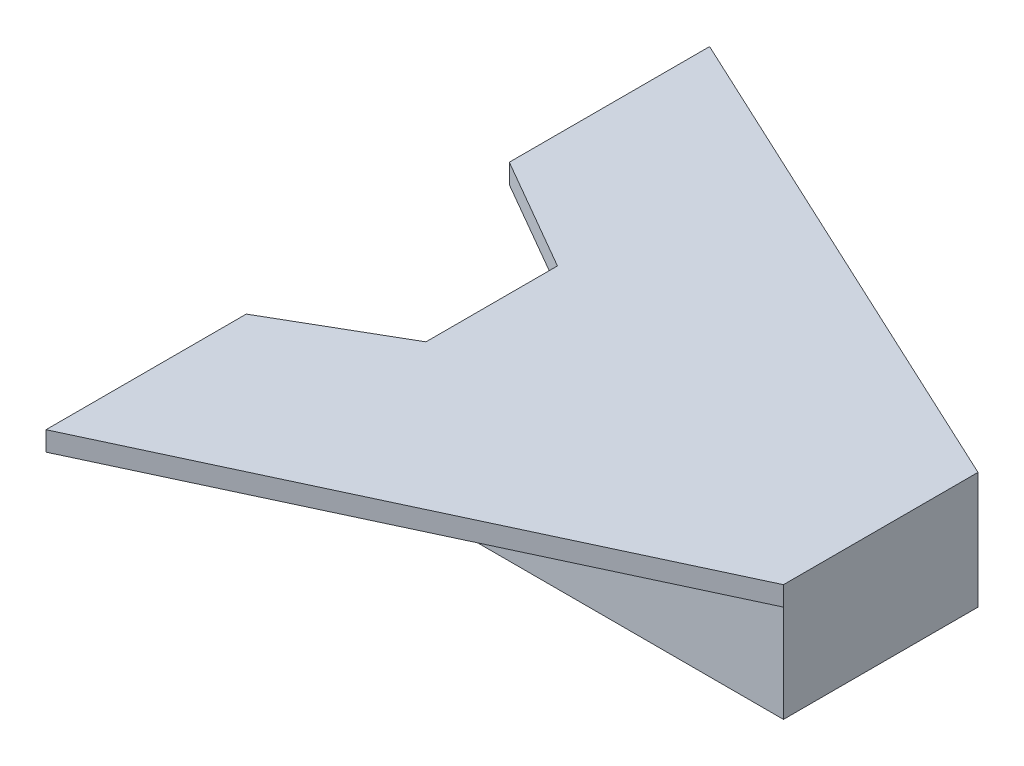
from build123d import *

# Parameters (mm, degrees)
BOSS_EXTRUDE1_DEPTH = 50
SKETCH2_W           = 950
SKETCH2_H           = 500
BOSS_EXTRUDE2_DEPTH = 250
SKETCH3_R           = 5
CUT_EXTRUDE1_DEPTH  = 500
SKETCH4_W           = 11.538461538
SKETCH4_H           = 3.076923077
BOSS_EXTRUDE3_DEPTH = 3


with BuildPart() as part:
    # Sketch1 → Boss-Extrude1 (new body)
    with BuildSketch(Plane(origin=(0, 0, 0), x_dir=(1, 0, 0), z_dir=(0, 1, 0))):
        Polygon((-1000, 500), (0, 500), (-1292.759621171, 1102.823711506), (-1292.759621171, 588.049692182), (-1000, 419.024846091), align=None)
        Polygon((0, 0), (0, 500), (-1000, 500), (-1000, 419.024846091), (-1000, 80.975153909), (-1000, 0), align=None)
        Polygon((-1292.759621171, -602.823711506), (0, 0), (-1000, 0), (-1000, 80.975153909), (-1292.759621171, -88.049692182), align=None)
    extrude(amount=BOSS_EXTRUDE1_DEPTH)

    # Sketch2 → Boss-Extrude2 (add)
    with BuildSketch(Plane.XZ):
        with Locations((-475, -250)):
            Rectangle(SKETCH2_W, SKETCH2_H)
    extrude(amount=BOSS_EXTRUDE2_DEPTH)

    # Sketch3 → Cut-Extrude1 (cut)
    with BuildSketch(Plane.XY):
        with Locations((-700, -170)):
            Circle(SKETCH3_R)
    extrude(amount=-CUT_EXTRUDE1_DEPTH, mode=Mode.SUBTRACT)

    # Sketch4 → Boss-Extrude3 (add)
    with BuildSketch(Plane.ZY.offset(950)):
        with BuildLine():
            Line((-305.64268199, -193.452389405), (-308.334989682, -193.452389405))
            add(Edge.make_bspline(
                [(-308.334989682, -193.452389405), (-308.317442657, -193.095210367), (-308.282980765, -192.393720242), (-308.121595428, -191.370943902), (-307.890673624, -190.393331341), (-307.564175447, -189.468732079), (-307.158693066, -188.588970874), (-306.672435688, -187.757542168), (-306.096488398, -186.977617693), (-305.44328782, -186.256427608), (-304.733842343, -185.594819858), (-303.968362862, -185.023489205), (-303.163976913, -184.540766308), (-302.323124922, -184.137212807), (-301.436320092, -183.834299842), (-300.511609882, -183.609542931), (-299.54493157, -183.47431711), (-298.886302809, -183.459781805), (-298.551335836, -183.452389405)],
                knots=[0, 0, 0, 0, 0.00107214, 0.002105654, 0.003101184, 0.004081912, 0.005041834, 0.006003467, 0.006966244, 0.007944944, 0.008918817, 0.009871943, 0.010804673, 0.011729393, 0.012664463, 0.013610438, 0.014581023, 0.01558551, 0.01558551, 0.01558551, 0.01558551], degree=3))
            add(Edge.make_bspline(
                [(-298.551335836, -183.452389405), (-298.222380915, -183.46009046), (-297.575996247, -183.475222759), (-296.632607552, -183.605174438), (-295.734516456, -183.808708081), (-294.883478457, -184.094268792), (-294.086283618, -184.478135313), (-293.336943236, -184.939257073), (-292.626536287, -185.472569913), (-291.98704957, -186.100459743), (-291.399837462, -186.770765895), (-290.893246704, -187.486376498), (-290.459419588, -188.225484661), (-290.097810904, -188.993726389), (-289.831615427, -189.798335204), (-289.629516501, -190.627596942), (-289.515281527, -191.490095322), (-289.497749325, -192.073865799), (-289.488835836, -192.370658636)],
                knots=[0, 0, 0, 0, 0.000986474, 0.001938387, 0.002850978, 0.003746088, 0.004625075, 0.005499097, 0.006382531, 0.007283573, 0.008182467, 0.009052929, 0.009909441, 0.010751002, 0.011594791, 0.0124475, 0.013308471, 0.014198888, 0.014198888, 0.014198888, 0.014198888], degree=3))
            add(Edge.make_bspline(
                [(-289.488835836, -192.370658636), (-289.503349518, -192.788497218), (-289.532122187, -193.616841907), (-289.778245414, -194.834112159), (-290.162644081, -196.013484322), (-290.625478568, -196.962661197), (-291.092385231, -197.727519715), (-291.513135297, -198.357251472), (-292.00569082, -199.035298344), (-292.577220802, -199.759389807), (-293.215902563, -200.535197565), (-293.927521106, -201.362252954), (-294.717150952, -202.232010981), (-295.271366673, -202.826058993), (-295.558547375, -203.13387979)],
                knots=[0, 0, 0, 0, 0.001252439, 0.0024829, 0.003710568, 0.004965773, 0.005639815, 0.006398194, 0.00723724, 0.008153308, 0.009165156, 0.010251767, 0.011426121, 0.012689069, 0.012689069, 0.012689069, 0.012689069], degree=3))
            Line((-295.558547375, -203.13387979), (-303.06455699, -211.144697097))
            Line((-303.06455699, -211.144697097), (-289.104220452, -211.144697097))
            Line((-289.104220452, -211.144697097), (-289.104220452, -214.221620174))
            Line((-289.104220452, -214.221620174), (-309.488835836, -214.221620174))
            Line((-309.488835836, -214.221620174), (-297.854220452, -201.80575479))
            add(Edge.make_bspline(
                [(-297.854220452, -201.80575479), (-297.57095285, -201.510055019), (-297.026853761, -200.942076277), (-296.257288817, -200.112850904), (-295.566097488, -199.343569127), (-294.94880555, -198.635684426), (-294.418804076, -197.978842416), (-293.948470659, -197.394316385), (-293.571622736, -196.856421097), (-293.16263363, -196.23293012), (-292.76651379, -195.471681688), (-292.426122167, -194.541392922), (-292.218566323, -193.583730757), (-292.193667733, -192.936570439), (-292.181143529, -192.611043251)],
                knots=[0, 0, 0, 0, 0.001228448, 0.002359598, 0.003393688, 0.004331034, 0.005176705, 0.005925692, 0.006580988, 0.007146084, 0.008162117, 0.009146888, 0.010111014, 0.011086814, 0.011086814, 0.011086814, 0.011086814], degree=3))
            add(Edge.make_bspline(
                [(-292.181143529, -192.611043251), (-292.186592748, -192.406345551), (-292.197332114, -192.00292569), (-292.292112378, -191.411447756), (-292.435345287, -190.840892209), (-292.640590356, -190.289504045), (-292.911505271, -189.762827027), (-293.241277099, -189.260220054), (-293.621763357, -188.774314638), (-294.061917094, -188.318714941), (-294.545444407, -187.901447465), (-295.056252261, -187.531812447), (-295.596681726, -187.222905783), (-296.164454201, -186.969675807), (-296.757986796, -186.771029683), (-297.378427469, -186.633384716), (-298.024061894, -186.546963425), (-298.464920429, -186.535270523), (-298.68955699, -186.529312482)],
                knots=[0, 0, 0, 0, 0.000613717, 0.001209518, 0.001792544, 0.002376343, 0.002970323, 0.003565396, 0.004177345, 0.004819137, 0.005462503, 0.006091248, 0.006707695, 0.007326422, 0.007953557, 0.008581928, 0.009230438, 0.009904185, 0.009904185, 0.009904185, 0.009904185], degree=3))
            add(Edge.make_bspline(
                [(-298.68955699, -186.529312482), (-298.924164128, -186.53544133), (-299.38489381, -186.547477376), (-300.061342664, -186.631671638), (-300.706649328, -186.776921699), (-301.322437068, -186.975578908), (-301.909747803, -187.228080755), (-302.465725324, -187.542581424), (-302.989121517, -187.917868508), (-303.480920289, -188.343358991), (-303.934040109, -188.817081287), (-304.332156188, -189.345166684), (-304.680019166, -189.917973102), (-304.983526882, -190.533954964), (-305.230004226, -191.19870165), (-305.418345515, -191.909853405), (-305.56737563, -192.664322389), (-305.617162949, -193.185337402), (-305.64268199, -193.452389405)],
                knots=[0, 0, 0, 0, 0.000703767, 0.001382082, 0.002041087, 0.002685351, 0.003320582, 0.00395567, 0.004597687, 0.00524953, 0.005904164, 0.006560424, 0.00722933, 0.007911997, 0.00861748, 0.009352228, 0.010117151, 0.010921497, 0.010921497, 0.010921497, 0.010921497], degree=3))
        make_face()
        Polygon((-283.719605067, -184.221620174), (-269.104220452, -184.221620174), (-269.104220452, -187.298543251), (-281.027297375, -187.298543251), (-281.027297375, -196.529312482), (-269.104220452, -196.529312482), (-269.104220452, -199.606235559), (-281.027297375, -199.606235559), (-281.027297375, -214.221620174), (-283.719605067, -214.221620174), align=None)
        with BuildLine():
            Line((-266.796528144, -208.434360559), (-264.260470452, -206.913927867))
            add(Edge.make_bspline(
                [(-264.260470452, -206.913927867), (-264.024599847, -207.308765452), (-263.57268087, -208.065259028), (-262.818812077, -209.087470803), (-262.037672838, -209.95628929), (-261.223478551, -210.666660212), (-260.381198996, -211.225936384), (-259.505335678, -211.621955513), (-258.598840157, -211.868949587), (-257.981921688, -211.898950329), (-257.67393199, -211.913927867)],
                knots=[0, 0, 0, 0, 0.001379151, 0.0026424, 0.003803812, 0.004877399, 0.005875827, 0.00682529, 0.007750887, 0.008673672, 0.008673672, 0.008673672, 0.008673672], degree=3))
            add(Edge.make_bspline(
                [(-257.67393199, -211.913927867), (-257.410901757, -211.906602102), (-256.889443702, -211.892078757), (-256.121767334, -211.752529025), (-255.376209029, -211.538139349), (-254.668134991, -211.231102793), (-254.007315438, -210.859630058), (-253.427829478, -210.410948537), (-252.926862794, -209.908609631), (-252.517070383, -209.348186877), (-252.202670081, -208.74546846), (-251.96102378, -208.126817449), (-251.826923149, -207.482515435), (-251.806722405, -207.048711468), (-251.796528144, -206.829793251)],
                knots=[0, 0, 0, 0, 0.000788383, 0.001562971, 0.002333163, 0.003111217, 0.003873017, 0.004601446, 0.005302617, 0.005994975, 0.006675125, 0.007337001, 0.007981713, 0.008638523, 0.008638523, 0.008638523, 0.008638523], degree=3))
            add(Edge.make_bspline(
                [(-251.796528144, -206.829793251), (-251.809165093, -206.58001454), (-251.834854163, -206.072250918), (-252.051981135, -205.323111036), (-252.393546108, -204.58174615), (-252.708654483, -204.123163874), (-252.872249298, -203.885081713)],
                knots=[0, 0, 0, 0, 0.000748119, 0.001520816, 0.00232208, 0.003187236, 0.003187236, 0.003187236, 0.003187236], degree=3))
            add(Edge.make_bspline(
                [(-252.872249298, -203.885081713), (-253.006568848, -203.713251796), (-253.288555942, -203.35251638), (-253.773334621, -202.815557219), (-254.342187029, -202.261685056), (-254.975646072, -201.669750282), (-255.696786833, -201.067283454), (-256.483022671, -200.425555357), (-257.354427176, -199.768970411), (-257.965565719, -199.328634135), (-258.280903144, -199.101427867)],
                knots=[0, 0, 0, 0, 0.000654165, 0.001373338, 0.002167995, 0.003035547, 0.003973548, 0.004986253, 0.006080019, 0.007246024, 0.007246024, 0.007246024, 0.007246024], degree=3))
            add(Edge.make_bspline(
                [(-258.280903144, -199.101427867), (-258.596537397, -198.876611401), (-259.200006053, -198.446779439), (-260.043936759, -197.808857005), (-260.798603585, -197.225623837), (-261.460652298, -196.691589448), (-262.029791699, -196.206681407), (-262.510506651, -195.775556215), (-262.890551426, -195.386554264), (-263.101884975, -195.134199907), (-263.196768529, -195.020899021)],
                knots=[0, 0, 0, 0, 0.001162484, 0.002222581, 0.00317343, 0.004023764, 0.004774028, 0.005416383, 0.005960377, 0.006403625, 0.006403625, 0.006403625, 0.006403625], degree=3))
            add(Edge.make_bspline(
                [(-263.196768529, -195.020899021), (-263.329390345, -194.844318705), (-263.590208945, -194.497049815), (-263.934488992, -193.95426532), (-264.227110387, -193.398637331), (-264.456501806, -192.828672777), (-264.649669396, -192.252373387), (-264.779594516, -191.662219852), (-264.860949347, -191.060860266), (-264.86928066, -190.656173117), (-264.873451221, -190.453591328)],
                knots=[0, 0, 0, 0, 0.000662313, 0.001302528, 0.001926139, 0.002543289, 0.00314383, 0.00374743, 0.004353448, 0.004960895, 0.004960895, 0.004960895, 0.004960895], degree=3))
            add(Edge.make_bspline(
                [(-264.873451221, -190.453591328), (-264.862263715, -190.136193261), (-264.840127829, -189.508181286), (-264.652923395, -188.590774168), (-264.35744145, -187.714890591), (-263.943485268, -186.889202017), (-263.409850814, -186.135207895), (-262.792313891, -185.444235149), (-262.056786866, -184.863361587), (-261.249764381, -184.355829658), (-260.366424049, -183.958578871), (-259.440787734, -183.658913327), (-258.47138426, -183.489119689), (-257.814785963, -183.464753133), (-257.481624298, -183.452389405)],
                knots=[0, 0, 0, 0, 0.000951419, 0.001882502, 0.002796616, 0.00371846, 0.004642066, 0.005560928, 0.006488222, 0.007443751, 0.008414597, 0.009385796, 0.010356028, 0.011355432, 0.011355432, 0.011355432, 0.011355432], degree=3))
            add(Edge.make_bspline(
                [(-257.481624298, -183.452389405), (-257.128103438, -183.464582705), (-256.42506328, -183.488831285), (-255.390927147, -183.699667268), (-254.395263863, -184.048530169), (-253.594321593, -184.444432952), (-252.967469352, -184.839845087), (-252.489417358, -185.200015009), (-252.004982065, -185.614658797), (-251.510255881, -186.084880906), (-251.013621657, -186.614995916), (-250.507706352, -187.201373249), (-249.991326905, -187.840429442), (-249.659133819, -188.296639449), (-249.488835836, -188.530514405)],
                knots=[0, 0, 0, 0, 0.001059756, 0.002107517, 0.003150925, 0.004217898, 0.004779757, 0.005372307, 0.006011759, 0.006691882, 0.007418847, 0.008189976, 0.009014959, 0.009882761, 0.009882761, 0.009882761, 0.009882761], degree=3))
            Line((-249.488835836, -188.530514405), (-251.922730067, -190.375466328))
            add(Edge.make_bspline(
                [(-251.922730067, -190.375466328), (-252.069695202, -190.186134696), (-252.352715692, -189.82152624), (-252.782397008, -189.310914963), (-253.187385418, -188.844487996), (-253.586388845, -188.439358327), (-253.958334258, -188.073340041), (-254.319337477, -187.759970697), (-254.664203345, -187.496179879), (-255.098919722, -187.214663651), (-255.645071593, -186.935607906), (-256.330653332, -186.699472951), (-257.047107118, -186.55757242), (-257.535075388, -186.538810527), (-257.782105067, -186.529312482)],
                knots=[0, 0, 0, 0, 0.000718947, 0.001384524, 0.002001878, 0.002571367, 0.003089868, 0.003567018, 0.004004524, 0.004391247, 0.005119601, 0.005837995, 0.006560475, 0.00730122, 0.00730122, 0.00730122, 0.00730122], degree=3))
            add(Edge.make_bspline(
                [(-257.782105067, -186.529312482), (-258.092018116, -186.539698482), (-258.689656237, -186.559726904), (-259.538143975, -186.778469635), (-260.30180619, -187.12288558), (-260.957971033, -187.605585392), (-261.504287979, -188.177479615), (-261.899477626, -188.835584087), (-262.137336179, -189.562290395), (-262.166361433, -190.069218878), (-262.181143529, -190.327389405)],
                knots=[0, 0, 0, 0, 0.000927839, 0.00178925, 0.002609402, 0.003426798, 0.004217605, 0.004966882, 0.00571188, 0.006485068, 0.006485068, 0.006485068, 0.006485068], degree=3))
            add(Edge.make_bspline(
                [(-262.181143529, -190.327389405), (-262.177773872, -190.488116364), (-262.171029048, -190.809833102), (-262.076959353, -191.285131005), (-261.956107962, -191.7592282), (-261.76459969, -192.229993195), (-261.500211373, -192.70565913), (-261.153024151, -193.194416881), (-260.715767191, -193.700574383), (-260.380821371, -194.029780444), (-260.203980067, -194.203591328)],
                knots=[0, 0, 0, 0, 0.00048137, 0.000963527, 0.001448968, 0.001947803, 0.002483063, 0.003078288, 0.003743159, 0.004486823, 0.004486823, 0.004486823, 0.004486823], degree=3))
            add(Edge.make_bspline(
                [(-260.203980067, -194.203591328), (-260.138311161, -194.262194407), (-259.982296871, -194.401421907), (-259.69707465, -194.629355741), (-259.320422094, -194.91052236), (-258.862174655, -195.258413644), (-258.313882983, -195.661969034), (-257.675486788, -196.116028567), (-256.954102221, -196.635332501), (-256.442200084, -196.998397135), (-256.171528144, -197.190370174)],
                knots=[0, 0, 0, 0, 0.000264013, 0.000627234, 0.001094789, 0.001674117, 0.00235323, 0.003137065, 0.004024292, 0.005019805, 0.005019805, 0.005019805, 0.005019805], degree=3))
            add(Edge.make_bspline(
                [(-256.171528144, -197.190370174), (-255.845934601, -197.427296113), (-255.215467832, -197.886070357), (-254.318402862, -198.575347614), (-253.505027364, -199.249471345), (-252.772485619, -199.904136549), (-252.113540689, -200.534377346), (-251.535503084, -201.147776034), (-251.032482966, -201.739938086), (-250.490946808, -202.499131592), (-249.937594069, -203.431540886), (-249.462381148, -204.573925788), (-249.16273817, -205.720751392), (-249.123553752, -206.491552847), (-249.104220452, -206.871860559)],
                knots=[0, 0, 0, 0, 0.001207992, 0.00233911, 0.003393262, 0.004376436, 0.005285975, 0.00612775, 0.006904131, 0.007614614, 0.008923607, 0.010146797, 0.011317207, 0.012457087, 0.012457087, 0.012457087, 0.012457087], degree=3))
            add(Edge.make_bspline(
                [(-249.104220452, -206.871860559), (-249.109853064, -207.140817974), (-249.121008908, -207.673509833), (-249.249245311, -208.455696206), (-249.437128156, -209.215389375), (-249.720304447, -209.94319891), (-250.065931517, -210.652439733), (-250.504499356, -211.324507451), (-251.01285094, -211.974276582), (-251.595997496, -212.584420793), (-252.23410523, -213.144531045), (-252.908536899, -213.642780143), (-253.620396381, -214.058222915), (-254.365821953, -214.397230133), (-255.144984839, -214.662374569), (-255.957622986, -214.854484875), (-256.805075939, -214.972390969), (-257.381080067, -214.984628924), (-257.67393199, -214.990850944)],
                knots=[0, 0, 0, 0, 0.000806095, 0.001596537, 0.002371964, 0.003149901, 0.00393468, 0.004734839, 0.005552346, 0.006406747, 0.007262669, 0.008096859, 0.008918332, 0.00973052, 0.010549615, 0.011383394, 0.012232453, 0.013110597, 0.013110597, 0.013110597, 0.013110597], degree=3))
            add(Edge.make_bspline(
                [(-257.67393199, -214.990850944), (-257.900520644, -214.986469387), (-258.350844302, -214.977761455), (-259.016925575, -214.900779052), (-259.669550625, -214.791861021), (-260.300530186, -214.618940421), (-260.917993714, -214.409137761), (-261.519255724, -214.150809196), (-262.104607614, -213.841233183), (-262.677329753, -213.487275829), (-263.235965535, -213.075352304), (-263.77527526, -212.595579478), (-264.312953993, -212.061189435), (-264.833131676, -211.45767032), (-265.346330056, -210.794772467), (-265.842430709, -210.066293752), (-266.331702575, -209.276202149), (-266.638692299, -208.7202157), (-266.796528144, -208.434360559)],
                knots=[0, 0, 0, 0, 0.000679512, 0.001350466, 0.002009472, 0.002662532, 0.003310596, 0.003964761, 0.004623356, 0.005295413, 0.005982929, 0.006702604, 0.007459005, 0.008255568, 0.009090991, 0.009972788, 0.010898386, 0.011877861, 0.011877861, 0.011877861, 0.011877861], degree=3))
        make_face()
        Polygon((-246.411912759, -187.298543251), (-246.411912759, -184.221620174), (-230.64268199, -184.221620174), (-230.64268199, -187.298543251), (-237.181143529, -187.298543251), (-237.181143529, -214.221620174), (-239.873451221, -214.221620174), (-239.873451221, -187.298543251), align=None)
        with Locations((-222.950374298, -202.683158636)):
            Rectangle(SKETCH4_W, SKETCH4_H)
        Polygon((-198.497249298, -183.452389405), (-197.950374298, -183.452389405), (-197.950374298, -204.221620174), (-194.488835836, -204.221620174), (-194.488835836, -207.298543251), (-197.950374298, -207.298543251), (-197.950374298, -214.221620174), (-200.64268199, -214.221620174), (-200.64268199, -207.298543251), (-214.873451221, -207.298543251), align=None)
        Polygon((-200.64268199, -204.221620174), (-200.64268199, -191.192774021), (-209.584989682, -204.221620174), align=None, mode=Mode.SUBTRACT)
        with BuildLine():
            Line((-189.104220452, -184.221620174), (-186.411912759, -184.221620174))
            Line((-186.411912759, -184.221620174), (-186.411912759, -202.19637979))
            add(Edge.make_bspline(
                [(-186.411912759, -202.19637979), (-186.412313422, -202.450786096), (-186.413073748, -202.933565904), (-186.407995058, -203.620722766), (-186.3937719, -204.231629558), (-186.384804818, -204.768641108), (-186.364856245, -205.22929323), (-186.348587272, -205.616081607), (-186.327668214, -205.927174771), (-186.302527207, -206.108725565), (-186.291720452, -206.186764405)],
                knots=[0, 0, 0, 0, 0.000763221, 0.001448344, 0.002061442, 0.002596433, 0.003059525, 0.003444562, 0.003757985, 0.003994279, 0.003994279, 0.003994279, 0.003994279], degree=3))
            add(Edge.make_bspline(
                [(-186.291720452, -206.186764405), (-186.247342233, -206.468308091), (-186.16108635, -207.015531484), (-185.941260255, -207.794745328), (-185.634253104, -208.49701497), (-185.270455595, -209.144254609), (-184.791033212, -209.718449123), (-184.216717195, -210.247406147), (-183.52090775, -210.710021615), (-182.747245416, -211.133028574), (-181.913371952, -211.473014994), (-181.061275383, -211.730100974), (-180.203764133, -211.886777258), (-179.629682718, -211.904919021), (-179.344605067, -211.913927867)],
                knots=[0, 0, 0, 0, 0.000854655, 0.001661154, 0.002420271, 0.003150037, 0.003880273, 0.004654418, 0.005484528, 0.006379981, 0.007296226, 0.008180375, 0.009046865, 0.009901583, 0.009901583, 0.009901583, 0.009901583], degree=3))
            add(Edge.make_bspline(
                [(-179.344605067, -211.913927867), (-179.099858721, -211.904723436), (-178.611779619, -211.886367736), (-177.886581641, -211.772698327), (-177.180294996, -211.567836336), (-176.489432025, -211.303495549), (-175.841852159, -210.954230483), (-175.237194084, -210.550766144), (-174.69750322, -210.077530064), (-174.205006095, -209.553812825), (-173.776135217, -208.962900254), (-173.404382574, -208.317659071), (-173.099874606, -207.608378955), (-172.949501536, -207.109912478), (-172.872249298, -206.853831713)],
                knots=[0, 0, 0, 0, 0.000734379, 0.001464516, 0.002195074, 0.002937207, 0.003679218, 0.004397612, 0.005113337, 0.005827698, 0.006550103, 0.007298487, 0.008057604, 0.008859611, 0.008859611, 0.008859611, 0.008859611], degree=3))
            add(Edge.make_bspline(
                [(-172.872249298, -206.853831713), (-172.846533938, -206.74798679), (-172.789229753, -206.512121646), (-172.735683654, -206.113367727), (-172.679913436, -205.642887465), (-172.641217121, -205.097300498), (-172.603492375, -204.478435018), (-172.58092318, -203.783067097), (-172.570491469, -203.013721719), (-172.56738278, -202.476831761), (-172.565758913, -202.19637979)],
                knots=[0, 0, 0, 0, 0.000326572, 0.000727733, 0.001205564, 0.001748063, 0.002368102, 0.003065632, 0.003834957, 0.004676324, 0.004676324, 0.004676324, 0.004676324], degree=3))
            Line((-172.565758913, -202.19637979), (-172.565758913, -184.221620174))
            Line((-172.565758913, -184.221620174), (-169.873451221, -184.221620174))
            Line((-169.873451221, -184.221620174), (-169.873451221, -202.340610559))
            add(Edge.make_bspline(
                [(-169.873451221, -202.340610559), (-169.875629396, -202.667168093), (-169.879880236, -203.304464975), (-169.91674232, -204.238333767), (-169.975516605, -205.124216463), (-170.058557359, -205.962232148), (-170.168588814, -206.749382084), (-170.290947847, -207.492565812), (-170.446772416, -208.186448606), (-170.628772998, -208.836440757), (-170.836831981, -209.455173729), (-171.106327538, -210.042390426), (-171.409966109, -210.615942423), (-171.770091706, -211.167154785), (-172.1747607, -211.698468097), (-172.632917963, -212.206660169), (-173.129410771, -212.699851994), (-173.67249271, -213.165392561), (-174.253211498, -213.592324077), (-174.869839707, -213.967733544), (-175.51764059, -214.285078837), (-176.194930243, -214.546301046), (-176.901997696, -214.742711896), (-177.638860779, -214.889070374), (-178.407196722, -214.972232924), (-178.929750918, -214.984592325), (-179.194364682, -214.990850944)],
                knots=[0, 0, 0, 0, 0.000979641, 0.001911829, 0.00280328, 0.003642843, 0.0044375, 0.005187378, 0.00590179, 0.006569615, 0.007211997, 0.007857577, 0.008505557, 0.009157316, 0.00983042, 0.010507162, 0.011208333, 0.01192861, 0.012651015, 0.013368352, 0.014091332, 0.01481231, 0.015542868, 0.016290093, 0.017063911, 0.017857749, 0.017857749, 0.017857749, 0.017857749], degree=3))
            add(Edge.make_bspline(
                [(-179.194364682, -214.990850944), (-179.48295699, -214.984124384), (-180.049174067, -214.970926899), (-180.883500357, -214.895303326), (-181.683336326, -214.752859946), (-182.457129557, -214.571489), (-183.194345247, -214.321342681), (-183.904860485, -214.029073039), (-184.576506323, -213.670125094), (-185.220178854, -213.270753154), (-185.818676764, -212.821399112), (-186.368083076, -212.331626193), (-186.869304824, -211.809280101), (-187.31389365, -211.248705537), (-187.709215518, -210.654262334), (-188.049760204, -210.02426885), (-188.342159439, -209.358968997), (-188.493072871, -208.896512994), (-188.569364682, -208.662725944)],
                knots=[0, 0, 0, 0, 0.000865906, 0.001698905, 0.002510047, 0.003301516, 0.004080683, 0.004842981, 0.005603737, 0.006362426, 0.007113628, 0.007845766, 0.00856837, 0.009282605, 0.009989316, 0.010707308, 0.011428562, 0.012165959, 0.012165959, 0.012165959, 0.012165959], degree=3))
            add(Edge.make_bspline(
                [(-188.569364682, -208.662725944), (-188.613740324, -208.503018163), (-188.709992078, -208.156608429), (-188.813066058, -207.58329567), (-188.89971533, -206.923167804), (-188.981191543, -206.176179647), (-189.029268325, -205.341752219), (-189.0714178, -204.420247226), (-189.10451739, -203.410550411), (-189.104322198, -202.707225992), (-189.104220452, -202.340610559)],
                knots=[0, 0, 0, 0, 0.000497057, 0.001078128, 0.001745304, 0.00249458, 0.003331666, 0.004252099, 0.005262161, 0.006361938, 0.006361938, 0.006361938, 0.006361938], degree=3))
            Line((-189.104220452, -202.340610559), (-189.104220452, -184.221620174))
        make_face()
    extrude(amount=BOSS_EXTRUDE3_DEPTH)


solid = part.part
